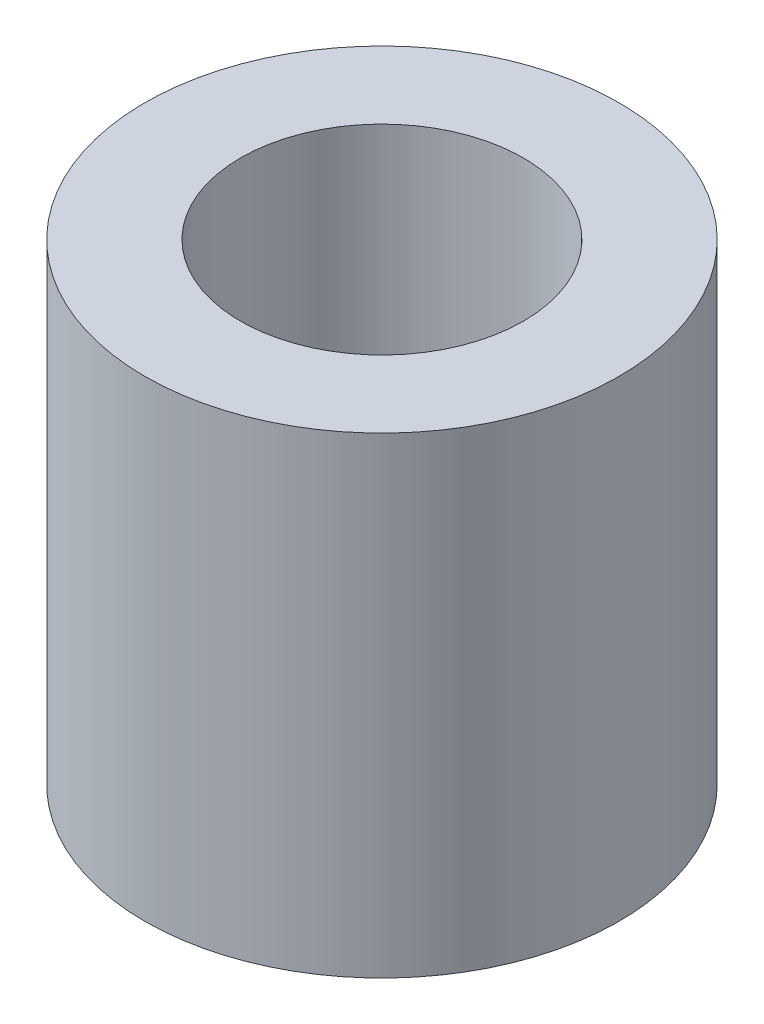
from build123d import *

# Parameters (mm, degrees)
SKETCH1_R           = 14.99997
SKETCH1_R_2         = 8.94969
EXTRUDE_THIN1_DEPTH = 29.86278


with BuildPart() as part:
    # Sketch1 → Extrude-Thin1 (new body)
    with BuildSketch(Plane(origin=(0, 0, 0), x_dir=(1, 0, 0), z_dir=(0, 1, 0))):
        Circle(SKETCH1_R)
        Circle(SKETCH1_R_2, mode=Mode.SUBTRACT)
    extrude(amount=EXTRUDE_THIN1_DEPTH)


solid = part.part
